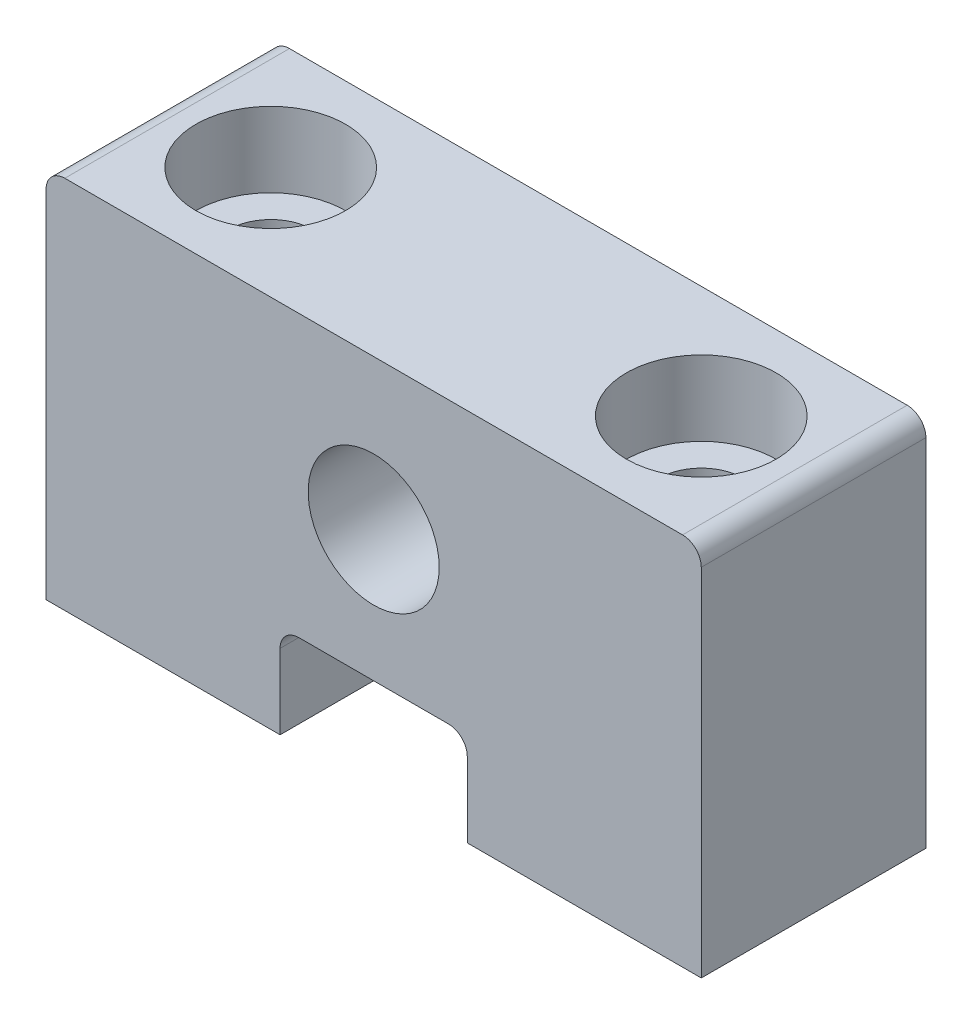
from build123d import *

# Parameters (mm, degrees)
SKETCH1_R                      = 3.5
BOSS_EXTRUDE1_DEPTH            = 12
CBORE_FOR_M4_SHCS1_D           = 4.5
CBORE_FOR_M4_SHCS1_CBORE_D     = 8
CBORE_FOR_M4_SHCS1_CBORE_DEPTH = 4
FILLET1_R                      = 1


with BuildPart() as part:
    # Sketch1 → Boss-Extrude1 (new body)
    with BuildSketch(Plane.XY):
        Polygon((-17.5, 20), (17.5, 20), (17.5, 0), (5, 0), (5, 5), (-5, 5), (-5, 0), (-17.5, 0), align=None)
        with Locations((0, 12)):
            Circle(SKETCH1_R, mode=Mode.SUBTRACT)
    extrude(amount=BOSS_EXTRUDE1_DEPTH)

    # CBORE for M4 SHCS1 (through all)
    with Locations(Plane(origin=(0, 20, 0), x_dir=(1, 0, 0), z_dir=(0, 1, 0))):
        with Locations((-11.5, -6), (11.5, -6)):
            CounterBoreHole(CBORE_FOR_M4_SHCS1_D / 2, CBORE_FOR_M4_SHCS1_CBORE_D / 2, CBORE_FOR_M4_SHCS1_CBORE_DEPTH)

    # Fillet1
    fillet1_edges = [part.edges().sort_by_distance(p)[0] for p in [
        (5, 5, 6),
        (-5, 5, 6),
        (-17.5, 20, 6),
        (17.5, 20, 6),
    ]]
    fillet(fillet1_edges, radius=FILLET1_R)


solid = part.part
